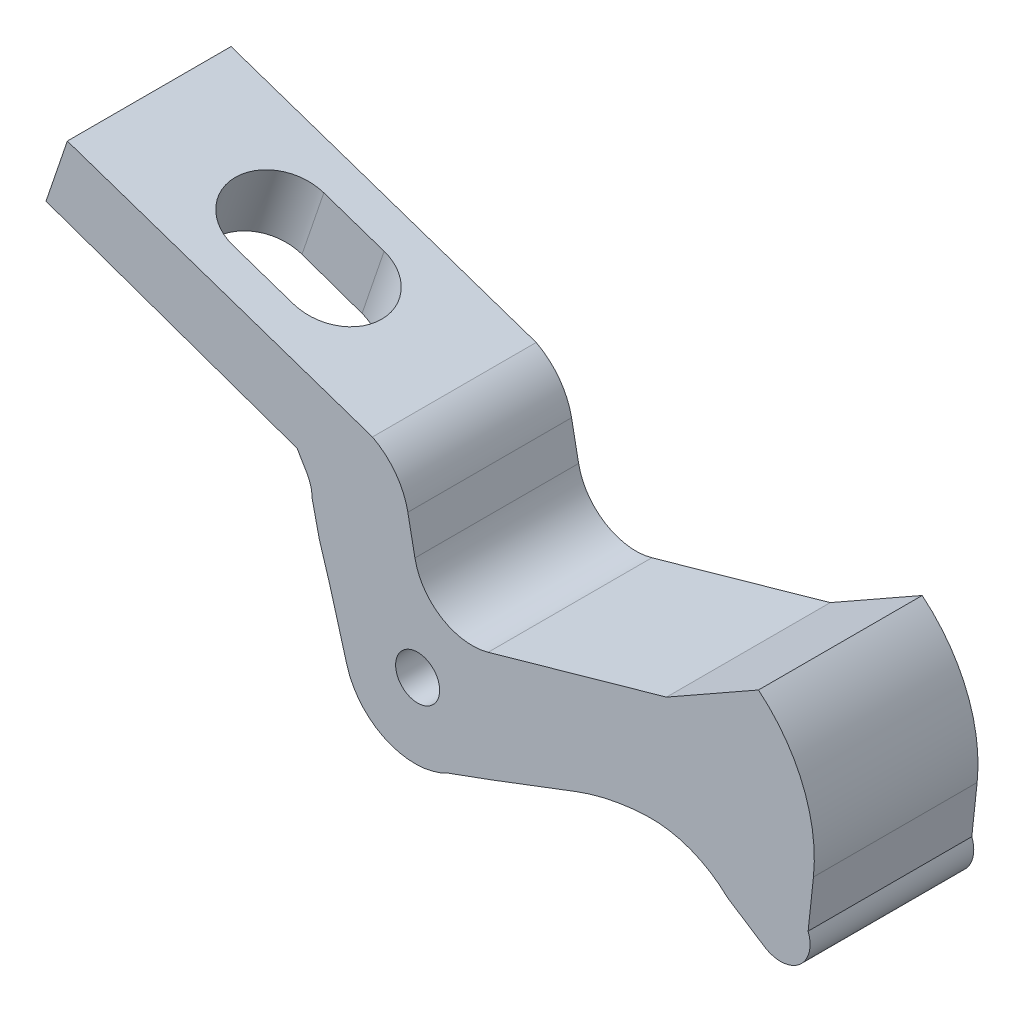
from build123d import *

# Parameters (mm, degrees)
ESQUISSE1_R             = 2.420540081
BOSS_EXTRU_1_DEPTH      = 18
ENL_V_MAT_EXTRU_1_DEPTH = 39.789502353


with BuildPart() as part:
    # Esquisse1 → Boss.-Extru.1 (new body)
    with BuildSketch(Plane.XY):
        with BuildLine():
            Line((7.309445695, 53.714347138), (40.857601275, 42.311087759))
            ThreePointArc((40.857601275, 42.311087759), (43.397194427, 40.141751778), (44.749299605, 37.087678504))
            Line((44.749299605, 37.087678504), (45.525391945, 33.121685243))
            ThreePointArc((45.525391945, 33.121685243), (48.466826033, 28.880719759), (53.578886424, 28.170324589))
            Line((53.578886424, 28.170324589), (60.334857797, 30.077073056))
            Line((60.334857797, 30.077073056), (73.18964939, 33.705101183))
            Line((73.18964939, 33.705101183), (77.686625145, 36.255437702))
            Line((77.686625145, 36.255437702), (83.301564432, 39.439796589))
            ThreePointArc((83.301564432, 39.439796589), (88.190630708, 32.808798216), (89.3438897, 24.651402666))
            Line((89.3438897, 24.651402666), (88.758364996, 19.199881093))
            ThreePointArc((88.758364996, 19.199881093), (87.769834705, 15.522983246), (83.96770833, 15.321476572))
            Line((83.96770833, 15.321476572), (79.922264923, 17.941129356))
            ThreePointArc((79.922264923, 17.941129356), (75.820018568, 20.528976888), (71.032935331, 21.309498572))
            ThreePointArc((71.032935331, 21.309498572), (67.034937106, 20.827330487), (63.167207989, 19.706104665))
            Line((63.167207989, 19.706104665), (53.880076109, 16.176154046))
            Line((53.880076109, 16.176154046), (49.199654782, 14.466799098))
            ThreePointArc((49.199654782, 14.466799098), (42.490348453, 14.160285015), (38.050617194, 19.199881093))
            Line((38.050617194, 19.199881093), (36.098238925, 26.117527504))
            Line((36.098238925, 26.117527504), (35.016515722, 29.633127914))
            Line((35.016515722, 29.633127914), (34.2322664, 33.121685243))
            ThreePointArc((34.2322664, 33.121685243), (34.067751372, 34.27153749), (33.610275558, 35.339217809))
            Line((33.610275558, 35.339217809), (32.57129733, 37.087678504))
            Line((32.57129733, 37.087678504), (4.96334494, 46.812166758))
            Line((4.96334494, 46.812166758), (7.309445695, 53.714347138))
        make_face()
        with Locations((45.822816194, 21.878618475)):
            Circle(ESQUISSE1_R, mode=Mode.SUBTRACT)
    extrude(amount=BOSS_EXTRU_1_DEPTH)

    # Esquisse2 → Enlèv. mat.-Extru.1 (cut, through all)
    with BuildSketch(Plane(origin=(17.123954965, 50.378324845, 0), x_dir=(0.946799522, -0.321823967, 0), z_dir=(0.321823967, 0.946799522, 0))):
        with BuildLine():
            Line((4.63401539, -14), (11.63401539, -14))
            ThreePointArc((11.63401539, -14), (16.63401539, -9), (11.63401539, -4))
            Line((11.63401539, -4), (4.63401539, -4))
            ThreePointArc((4.63401539, -4), (-0.36598461, -9), (4.63401539, -14))
        make_face()
    extrude(amount=-ENL_V_MAT_EXTRU_1_DEPTH, mode=Mode.SUBTRACT)


solid = part.part
